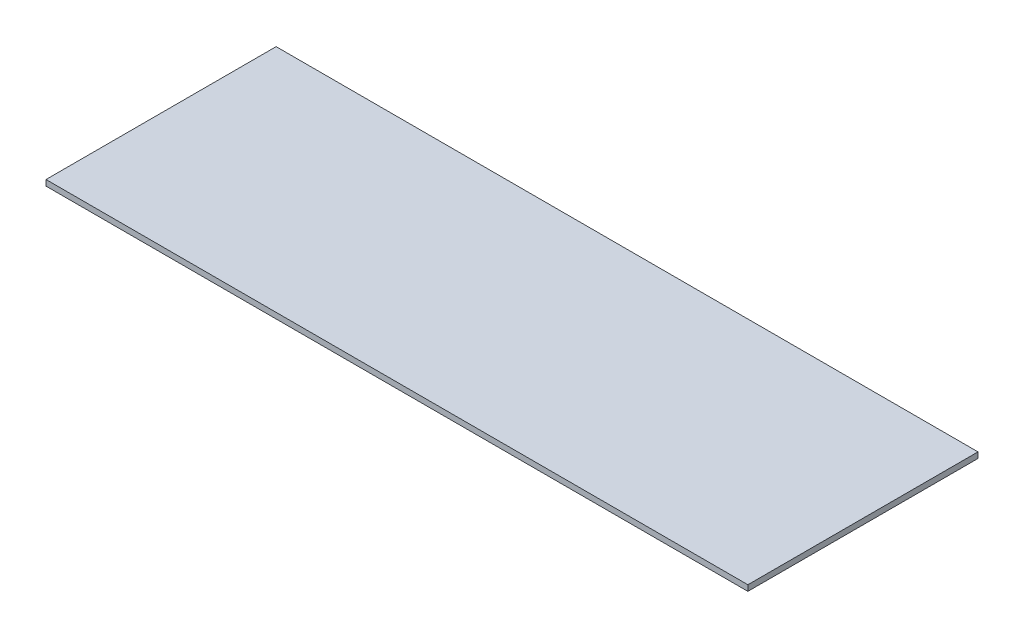
from build123d import *

# Parameters (mm, degrees)
SKETCH1_W           = 1220
SKETCH1_H           = 400
BOSS_EXTRUDE1_DEPTH = 10


with BuildPart() as part:
    # Sketch1 → Boss-Extrude1 (new body)
    with BuildSketch(Plane(origin=(0, 0, 0), x_dir=(1, 0, 0), z_dir=(0, 1, 0))):
        with Locations((536.797813746, 169.58500712)):
            Rectangle(SKETCH1_W, SKETCH1_H)
    extrude(amount=BOSS_EXTRUDE1_DEPTH)


solid = part.part
